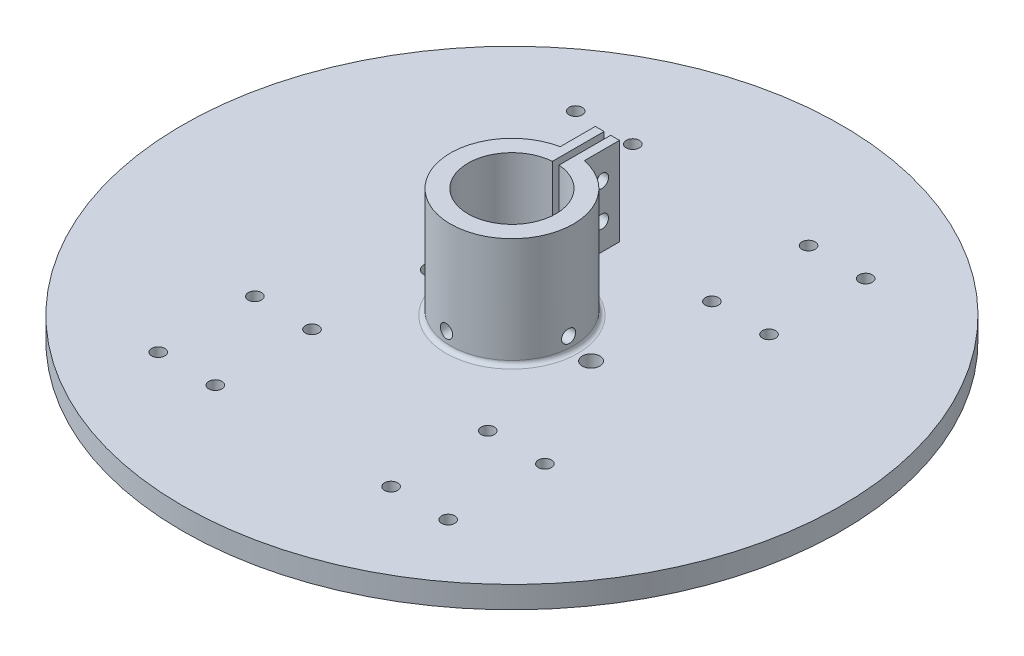
from build123d import *

# Parameters (mm, degrees)
SKETCH1_R               = 75
BOSS_EXTRUDE1_DEPTH     = 5
SKETCH2_R               = 14
SKETCH2_R_2             = 10
SKETCH2_R_3             = 4
BOSS_EXTRUDE2_DEPTH     = 25
SKETCH3_R               = 4
CUT_EXTRUDE1_DEPTH      = 12
CUT_EXTRUDE2_REACH      = 122.192
CUT_EXTRUDE2_END_RADIUS = 10
SKETCH4_R               = 1.5
CUT_EXTRUDE3_REACH      = 122.192
CUT_EXTRUDE3_END_RADIUS = 10
SKETCH5_R               = 1.5
SKETCH6_R               = 2
CUT_EXTRUDE4_DEPTH      = 111.227038452
SKETCH7_R               = 1.5
CUT_EXTRUDE5_DEPTH      = 111.227038452
CUT_EXTRUDE6_DEPTH      = 25
BOSS_EXTRUDE3_DEPTH     = 20
SKETCH10_R              = 1.5
CUT_EXTRUDE7_DEPTH      = 113.116290101
FILLET1_R               = 1


with BuildPart() as part:
    # Sketch1 → Boss-Extrude1 (new body)
    with BuildSketch(Plane(origin=(0, 0, 0), x_dir=(1, 0, 0), z_dir=(0, 1, 0))):
        with Locations(Location((0, 0, 0), (0, 0, 270))):
            Circle(SKETCH1_R)
    extrude(amount=BOSS_EXTRUDE1_DEPTH)

    # Sketch2 → Boss-Extrude2 (add)
    with BuildSketch(Plane(origin=(0, 5, 0), x_dir=(1, 0, 0), z_dir=(0, 1, 0))):
        with Locations(Location((0, 0, 0), (0, 0, 270))):
            Circle(SKETCH2_R)
        with Locations(Location((0, 0, 0), (0, 0, 270))):
            Circle(SKETCH2_R_2, mode=Mode.SUBTRACT)
        with Locations(Location((0, 0, 0), (0, 0, 270))):
            Circle(SKETCH2_R_3)
    extrude(amount=BOSS_EXTRUDE2_DEPTH)

    # Sketch3 → Cut-Extrude1 (cut)
    with BuildSketch(Plane(origin=(0, 30, 0), x_dir=(1, 0, 0), z_dir=(0, 1, 0))):
        with Locations(Location((0, 0, 0), (0, 0, 270))):
            Circle(SKETCH3_R)
    extrude(amount=-CUT_EXTRUDE1_DEPTH, mode=Mode.SUBTRACT)

    # Cut-Extrude2: up to this cylinder (the profile starts outside it)
    cut_extrude2_end = Plane(origin=(0, 8.4, 0), z_dir=(0, -1, 0)) * Cylinder(CUT_EXTRUDE2_END_RADIUS, 265.384, mode=Mode.PRIVATE)
    # Sketch4 → Cut-Extrude2 (cut, up to the surface)
    with BuildSketch(Plane(origin=(14, 0, 0), x_dir=(0, 0, -1), z_dir=(1, 0, 0)), mode=Mode.PRIVATE) as cut_extrude2_sk1:
        with Locations((-1, 8.4)):
            Circle(SKETCH4_R)
    cut_extrude2_tool1 = extrude(cut_extrude2_sk1.sketch, amount=-CUT_EXTRUDE2_REACH, mode=Mode.PRIVATE) - cut_extrude2_end
    add(cut_extrude2_tool1.solids().sort_by_distance((14, 8.4, 1))[0], mode=Mode.SUBTRACT)

    # Cut-Extrude3: up to this cylinder (the profile starts outside it)
    cut_extrude3_end = Plane(origin=(0, 8.4, 0), z_dir=(0, -1, 0)) * Cylinder(CUT_EXTRUDE3_END_RADIUS, 265.384, mode=Mode.PRIVATE)
    # Sketch5 → Cut-Extrude3 (cut, up to the surface)
    with BuildSketch(Plane.XY.offset(14), mode=Mode.PRIVATE) as cut_extrude3_sk1:
        with Locations((-1, 8.4)):
            Circle(SKETCH5_R)
    cut_extrude3_tool1 = extrude(cut_extrude3_sk1.sketch, amount=-CUT_EXTRUDE3_REACH, mode=Mode.PRIVATE) - cut_extrude3_end
    add(cut_extrude3_tool1.solids().sort_by_distance((-1, 8.4, 14))[0], mode=Mode.SUBTRACT)

    # Sketch6 → Cut-Extrude4 (cut, through all)
    with BuildSketch(Plane.XZ):
        with Locations(Location((-18, 0, 0), (0, 0, 270))):
            Circle(SKETCH6_R)
        with Locations(Location((18, 0, 0), (0, 0, 270))):
            Circle(SKETCH6_R)
    extrude(amount=-CUT_EXTRUDE4_DEPTH, mode=Mode.SUBTRACT)

    # Sketch7 → Cut-Extrude5 (cut, through all)
    with BuildSketch(Plane.XZ):
        with Locations(Location((20, 47.5, 0), (0, 0, 270))):
            Circle(SKETCH7_R)
        with Locations(Location((33, 47.5, 0), (0, 0, 270))):
            Circle(SKETCH7_R)
        with Locations(Location((20, 25.5, 0), (0, 0, 270))):
            Circle(SKETCH7_R)
        with Locations(Location((33, 25.5, 0), (0, 0, 270))):
            Circle(SKETCH7_R)
        with Locations(Location((-20, 25.5, 0), (0, 0, 270))):
            Circle(SKETCH7_R)
        with Locations(Location((-33, 25.5, 0), (0, 0, 270))):
            Circle(SKETCH7_R)
        with Locations(Location((-33, 47.5, 0), (0, 0, 270))):
            Circle(SKETCH7_R)
        with Locations(Location((-20, 47.5, 0), (0, 0, 270))):
            Circle(SKETCH7_R)
        with Locations(Location((-33, -47.5, 0), (0, 0, 270))):
            Circle(SKETCH7_R)
        with Locations(Location((-20, -47.5, 0), (0, 0, 270))):
            Circle(SKETCH7_R)
        with Locations(Location((-20, -25.5, 0), (0, 0, 270))):
            Circle(SKETCH7_R)
        with Locations(Location((-33, -25.5, 0), (0, 0, 270))):
            Circle(SKETCH7_R)
        with Locations(Location((20, -25.5, 0), (0, 0, 270))):
            Circle(SKETCH7_R)
        with Locations(Location((20, -47.5, 0), (0, 0, 270))):
            Circle(SKETCH7_R)
        with Locations(Location((33, -47.5, 0), (0, 0, 270))):
            Circle(SKETCH7_R)
        with Locations(Location((33, -25.5, 0), (0, 0, 270))):
            Circle(SKETCH7_R)
    extrude(amount=-CUT_EXTRUDE5_DEPTH, mode=Mode.SUBTRACT)

    # Sketch8 → Cut-Extrude6 (cut)
    with BuildSketch(Plane(origin=(0, 30, 0), x_dir=(1, 0, 0), z_dir=(0, 1, 0))):
        with BuildLine():
            Line((0.75, 13.97989628), (0.75, 9.971835338))
            ThreePointArc((0.75, 9.971835338), (0, 10), (-0.75, 9.971835338))
            Line((-0.75, 9.971835338), (-0.75, 13.97989628))
            ThreePointArc((-0.75, 13.97989628), (0, 14), (0.75, 13.97989628))
        make_face()
    extrude(amount=-CUT_EXTRUDE6_DEPTH, mode=Mode.SUBTRACT)

    # Sketch9 → Boss-Extrude3 (add)
    with BuildSketch(Plane(origin=(0, 30, 0), x_dir=(1, 0, 0), z_dir=(0, 1, 0))):
        with BuildLine():
            Line((0.75, 13.97989628), (0.75, 21.727253913))
            Line((0.75, 21.727253913), (2.75, 21.727253913))
            Line((2.75, 21.727253913), (2.75, 13.727253913))
            ThreePointArc((2.75, 13.727253913), (1.754553231, 13.889619972), (0.75, 13.97989628))
        make_face()
        with BuildLine():
            Line((-0.75, 21.727253913), (-2.75, 21.727253913))
            Line((-2.75, 21.727253913), (-2.75, 13.727253913))
            ThreePointArc((-2.75, 13.727253913), (-1.754553231, 13.889619972), (-0.75, 13.97989628))
            Line((-0.75, 13.97989628), (-0.75, 21.727253913))
        make_face()
    extrude(amount=-BOSS_EXTRUDE3_DEPTH)

    # Sketch10 → Cut-Extrude7 (cut, through all)
    with BuildSketch(Plane(origin=(2.75, 0, 0), x_dir=(0, 0, -1), z_dir=(1, 0, 0))):
        with Locations(Location((17.727253913, 24, 0), (0, 0, 180))):
            Circle(SKETCH10_R)
        with Locations(Location((17.727253913, 16, 0), (0, 0, 180))):
            Circle(SKETCH10_R)
    extrude(amount=-CUT_EXTRUDE7_DEPTH, mode=Mode.SUBTRACT)

    # Fillet1
    fillet1_edges = [part.edges().sort_by_distance(p)[0] for p in [
        (13.994973168, 5, 0.375134696),
    ]]
    fillet(fillet1_edges, radius=FILLET1_R)


solid = part.part
